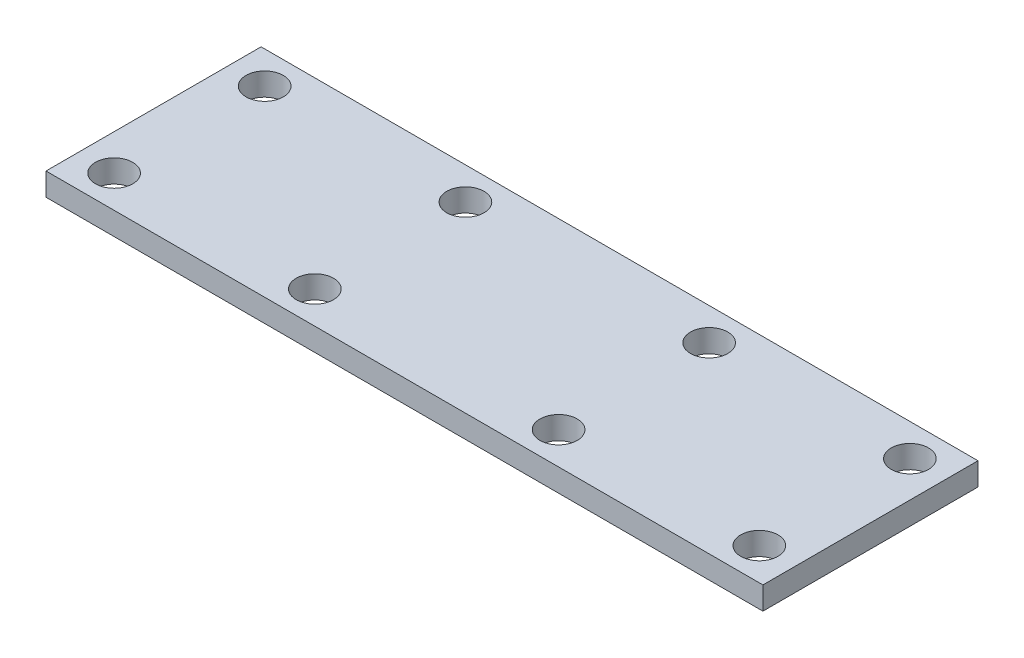
from build123d import *

# Parameters (mm, degrees)
SKETCH2_W           = 100
SKETCH2_H           = 30
SKETCH2_R           = 2.6
BOSS_EXTRUDE1_DEPTH = 3.175


with BuildPart() as part:
    # Sketch2 → Boss-Extrude1 (new body)
    with BuildSketch(Plane(origin=(0, 0, 0), x_dir=(1, 0, 0), z_dir=(0, 1, 0))):
        Rectangle(SKETCH2_W, SKETCH2_H)
        with Locations((-17, 10.5)):
            Circle(SKETCH2_R, mode=Mode.SUBTRACT)
        with Locations((17, 10.5)):
            Circle(SKETCH2_R, mode=Mode.SUBTRACT)
        with Locations((17, -10.5)):
            Circle(SKETCH2_R, mode=Mode.SUBTRACT)
        with Locations((-17, -10.5)):
            Circle(SKETCH2_R, mode=Mode.SUBTRACT)
        with Locations((-45, 10.5)):
            Circle(SKETCH2_R, mode=Mode.SUBTRACT)
        with Locations((45, 10.5)):
            Circle(SKETCH2_R, mode=Mode.SUBTRACT)
        with Locations((45, -10.5)):
            Circle(SKETCH2_R, mode=Mode.SUBTRACT)
        with Locations((-45, -10.5)):
            Circle(SKETCH2_R, mode=Mode.SUBTRACT)
    extrude(amount=BOSS_EXTRUDE1_DEPTH)


solid = part.part
